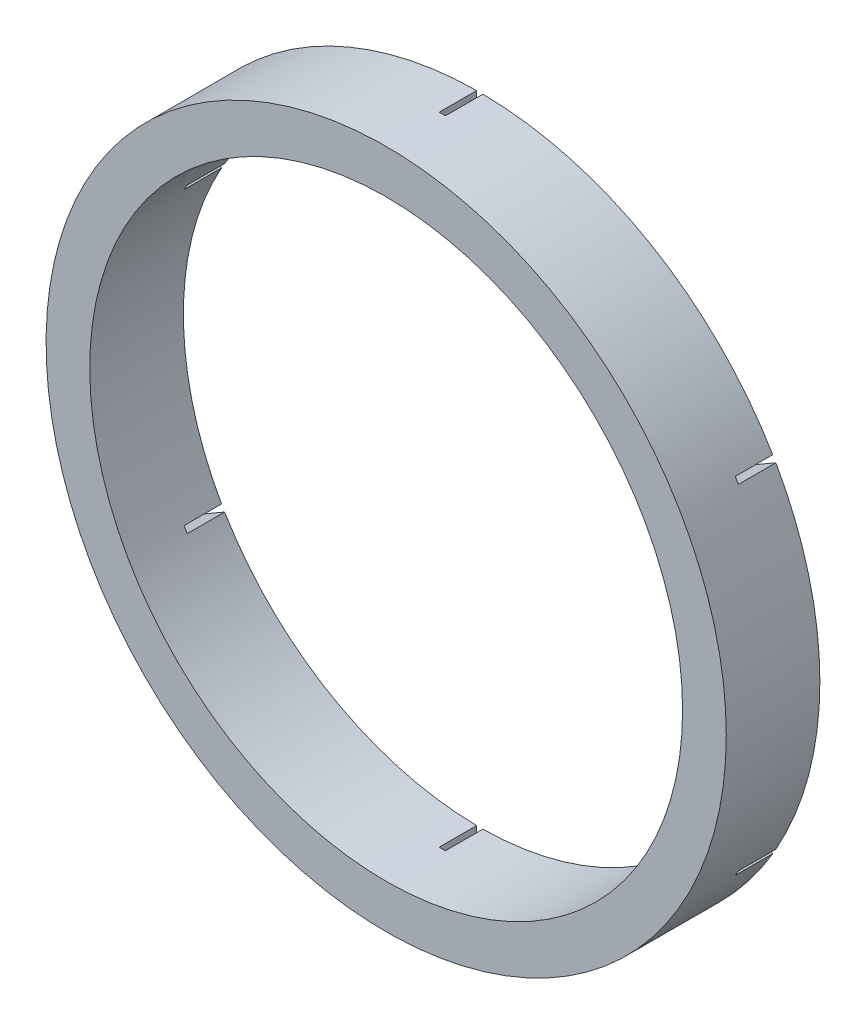
from build123d import *

# Parameters (mm, degrees)
ESQUISSE1_R             = 54.5
ESQUISSE1_R_2           = 47.5
BOSS_EXTRU_1_DEPTH      = 15
ESQUISSE2_W             = 1
ESQUISSE2_H             = 10.244333075
ENL_V_MAT_EXTRU_1_DEPTH = 6


with BuildPart() as part:
    # Esquisse1 → Boss.-Extru.1 (new body)
    with BuildSketch(Plane.XY):
        Circle(ESQUISSE1_R)
        Circle(ESQUISSE1_R_2, mode=Mode.SUBTRACT)
    extrude(amount=BOSS_EXTRU_1_DEPTH)

    # Esquisse2 → Enlèv. mat.-Extru.1 (cut)
    with BuildSketch(Plane(origin=(0, 0, 0), x_dir=(-1, 0, 0), z_dir=(0, 0, -1))):
        Polygon((48.965976814, 27.693169625), (40.094124126, 22.571003088), (39.594124126, 23.437028491), (48.465976814, 28.559195029), align=None)
        with Locations((0, 51.130198117)):
            Rectangle(ESQUISSE2_W, ESQUISSE2_H)
        Polygon((48.465976814, -28.559195029), (39.594124126, -23.437028491), (40.094124126, -22.571003088), (48.965976814, -27.693169625), align=None)
        with Locations((0, -51.130198117)):
            Rectangle(ESQUISSE2_W, ESQUISSE2_H)
        Polygon((-48.965976814, -27.693169625), (-40.094124126, -22.571003088), (-39.594124126, -23.437028491), (-48.465976814, -28.559195029), align=None)
        Polygon((-48.465976814, 28.559195029), (-39.594124126, 23.437028491), (-40.094124126, 22.571003088), (-48.965976814, 27.693169625), align=None)
    extrude(amount=-ENL_V_MAT_EXTRU_1_DEPTH, mode=Mode.SUBTRACT)


solid = part.part
